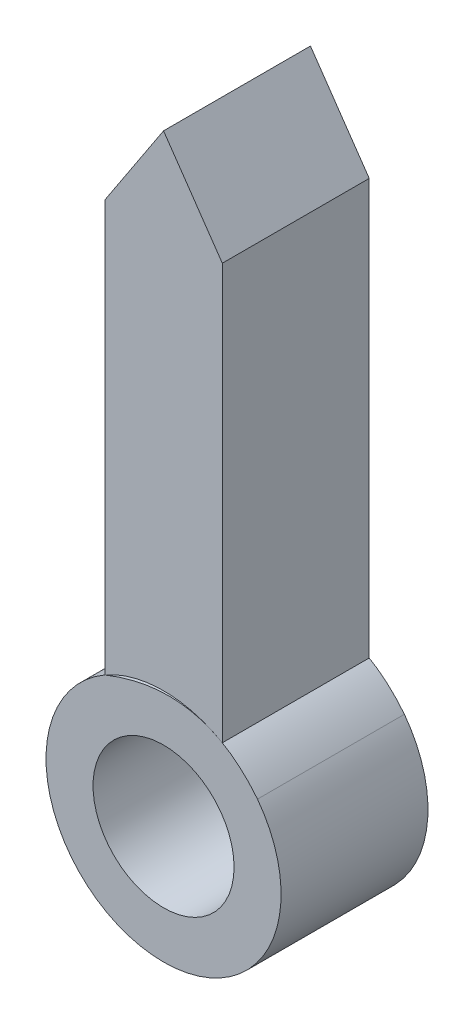
from build123d import *

# Parameters (mm, degrees)
SKETCH1_R           = 1.524
BOSS_EXTRUDE1_DEPTH = 3.175
BOSS_EXTRUDE2_DEPTH = 3.175


with BuildPart() as part:
    # Sketch1 → Boss-Extrude1 (new body)
    with BuildSketch(Plane.XY):
        with BuildLine():
            ThreePointArc((-1.27, 2.199704526), (-0.507928763, -2.488696119), (2.030417223, 1.52610809))
            add(Edge.make_bspline(
                [(2.030417223, 1.52610809), (0.827273923, 3.041818161), (-1.27, 2.199704526)],
                knots=[0.714314334, 0.714314334, 0.714314334, 1.714314334, 1.714314334, 1.714314334], degree=2))
        make_face()
        Circle(SKETCH1_R, mode=Mode.SUBTRACT)
    extrude(amount=BOSS_EXTRUDE1_DEPTH)


with BuildPart() as body_2:
    # Sketch1_4 → Boss-Extrude2 (new body)
    with BuildSketch(Plane.XY):
        with BuildLine():
            Line((-1.27, 11.089704526), (-1.27, 2.199704526))
            ThreePointArc((-1.27, 2.199704526), (0, 2.54), (1.27, 2.199704526))
            Line((1.27, 2.199704526), (1.27, 11.089704526))
            Line((1.27, 11.089704526), (1.27, 11.176))
            Line((1.27, 11.176), (0, 13.019186633))
            Line((0, 13.019186633), (-1.27, 11.089704526))
        make_face()
    extrude(amount=BOSS_EXTRUDE2_DEPTH)


solid = Compound([part.part, body_2.part])
